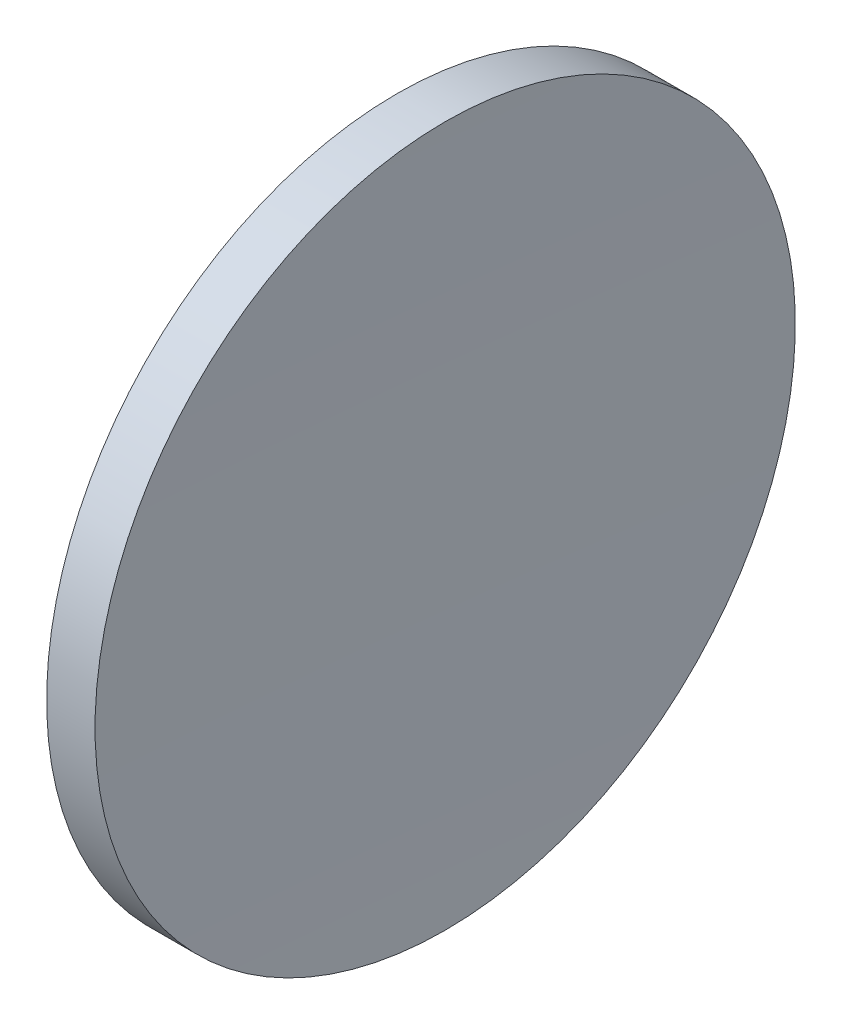
from build123d import *


with BuildPart() as part:
    # 草图1 → 旋转1 (revolve)
    with BuildSketch(Plane.XY):
        with BuildLine():
            Line((245.987314079, 155.433680942), (249.442576051, 155.433680942))
            ThreePointArc((249.442576051, 155.433680942), (249.24724412, 142.934359239), (249.182131121, 130.433680942))
            Line((249.182131121, 130.433680942), (245.282131121, 130.433680942))
            ThreePointArc((245.282131121, 130.433680942), (245.458461914, 142.938652783), (245.987314079, 155.433680942))
        make_face()
    revolve(axis=Axis((231.888982596, 130.433680942, 0), (1, 0, 0)))


solid = part.part
